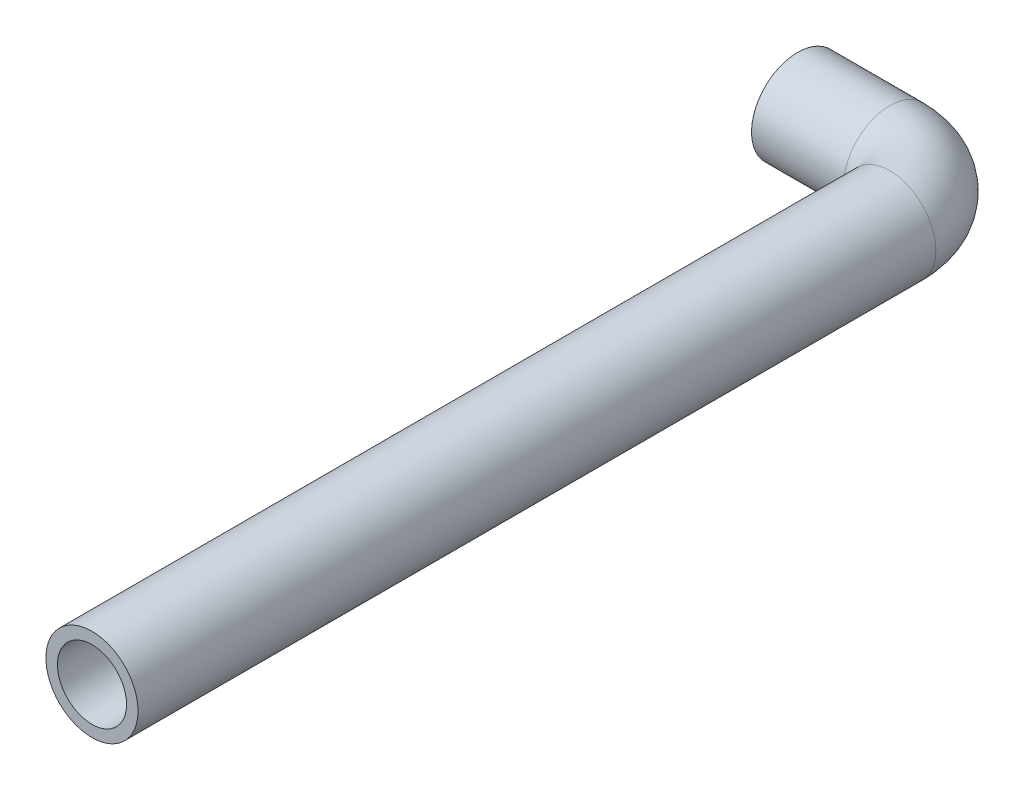
from build123d import *

# Parameters (mm, degrees)
SKETCH11_R   = 6.35
SKETCH11_R_2 = 4.7625


with BuildPart() as part:
    # Sweep4: sweep along a path in Sketch10
    with BuildLine(Plane(origin=(0, 0, 0), x_dir=(1, 0, 0), z_dir=(0, 1, 0))) as sweep4_path:
        Line((20.474871748, -106.555716131), (20.474871748, 3.409848368))
        ThreePointArc((20.474871748, 3.409848368), (18.197664536, 8.907512904), (12.7, 11.184720116))
        Line((12.7, 11.184720116), (0, 11.184720116))
    # Sketch11 → Sweep4 (sweep)
    with BuildSketch(Plane(origin=(0, 0, 0), x_dir=(0, 0, -1), z_dir=(1, 0, 0))):
        with Locations((11.184720116, 0)):
            Circle(SKETCH11_R)
        with Locations((11.184720116, 0)):
            Circle(SKETCH11_R_2, mode=Mode.SUBTRACT)
    sweep(path=sweep4_path.line)


solid = part.part
